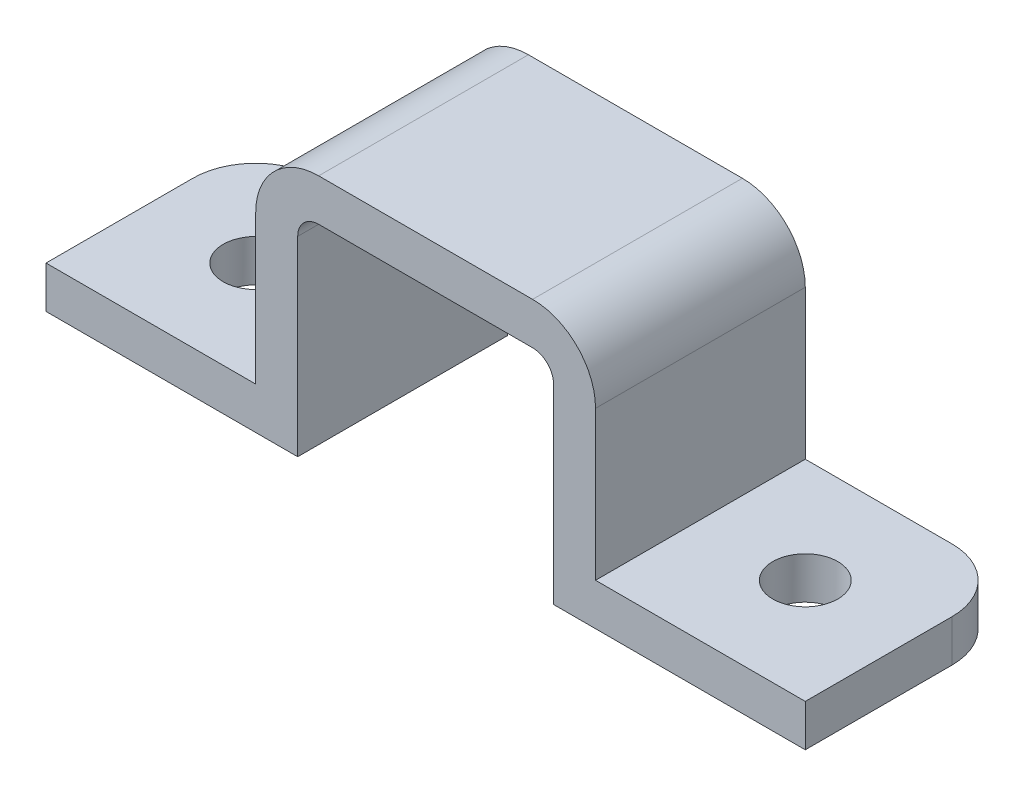
from build123d import *

# Parameters (mm, degrees)
BOSS_EXTRUDE1_DEPTH = 10
SKETCH2_R           = 1.55
CUT_EXTRUDE1_DEPTH  = 10
SKETCH3_R           = 1.55
CUT_EXTRUDE2_DEPTH  = 10
FILLET1_R           = 3
FILLET2_R           = 3
FILLET3_R           = 1


with BuildPart() as part:
    # Sketch1 → Boss-Extrude1 (new body)
    with BuildSketch(Plane.XY):
        Polygon((6.1, 10.1), (-6.1, 10.1), (-6.1, 0), (-18.1, 0), (-18.1, 2), (-8.1, 2), (-8.1, 12.1), (8.1, 12.1), (8.1, 2), (18.1, 2), (18.1, 0), (6.1, 0), align=None)
    extrude(amount=BOSS_EXTRUDE1_DEPTH)

    # Sketch2 → Cut-Extrude1 (cut)
    with BuildSketch(Plane(origin=(0, 2, 0), x_dir=(1, 0, 0), z_dir=(0, 1, 0))):
        with Locations((-13.1, -5)):
            Circle(SKETCH2_R)
    extrude(amount=-CUT_EXTRUDE1_DEPTH, mode=Mode.SUBTRACT)

    # Sketch3 → Cut-Extrude2 (cut)
    with BuildSketch(Plane(origin=(0, 2, 0), x_dir=(1, 0, 0), z_dir=(0, 1, 0))):
        with Locations((13.1, -5)):
            Circle(SKETCH3_R)
    extrude(amount=-CUT_EXTRUDE2_DEPTH, mode=Mode.SUBTRACT)

    # Fillet1
    fillet1_edges = [part.edges().sort_by_distance(p)[0] for p in [
        (-18.1, 1, 0),
        (18.1, 1, 0),
    ]]
    fillet(fillet1_edges, radius=FILLET1_R)

    # Fillet2
    fillet2_edges = [part.edges().sort_by_distance(p)[0] for p in [
        (-8.1, 12.1, 5),
        (8.1, 12.1, 5),
    ]]
    fillet(fillet2_edges, radius=FILLET2_R)

    # Fillet3
    fillet3_edges = [part.edges().sort_by_distance(p)[0] for p in [
        (6.1, 10.1, 5),
        (-6.1, 10.1, 5),
    ]]
    fillet(fillet3_edges, radius=FILLET3_R)


solid = part.part
